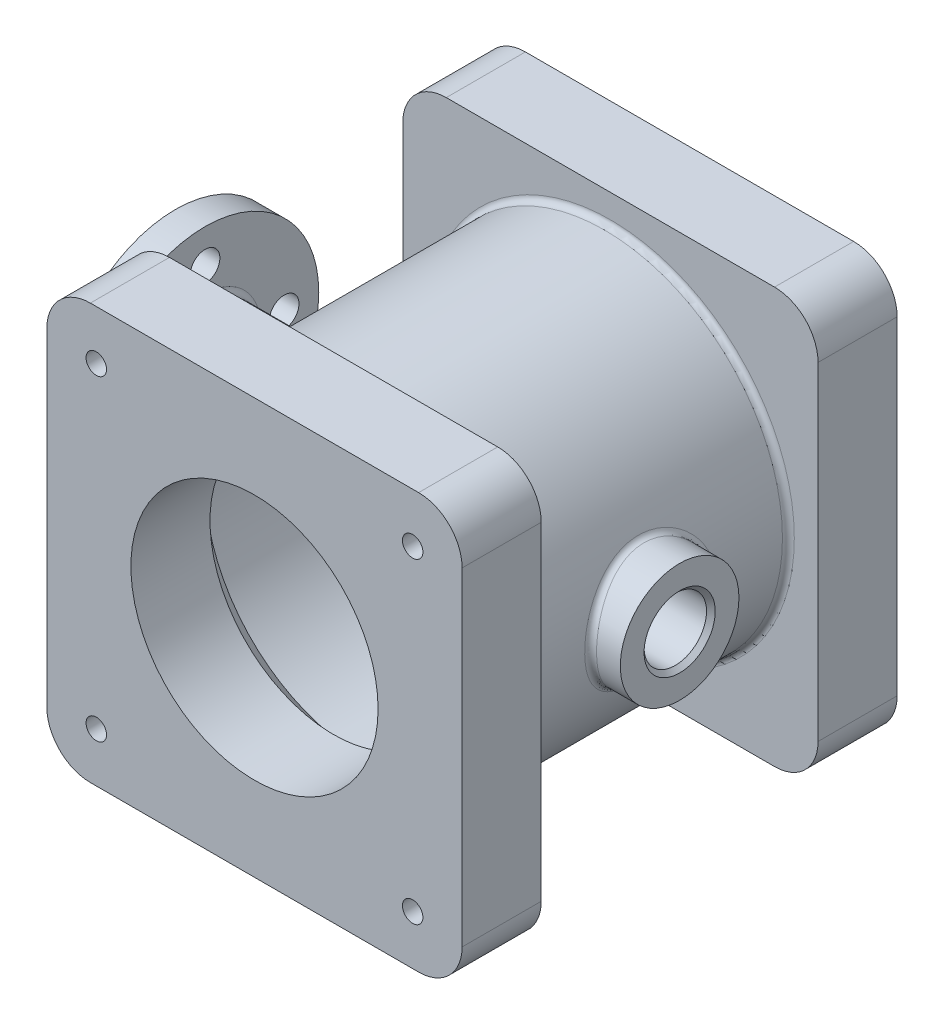
from build123d import *

# Parameters (mm, degrees)
EXTRUDE_1_DEPTH          = 40
SKETCH_2_R               = 90
SKETCH_2_R_2             = 80
EXTRUDE_2_DEPTH          = 70
CHAMFER_1_SIZE           = 15
SKETCH_3_R               = 30
CUT_EXTRUDE_1_DEPTH      = 165.164551594
SKETCH_4_R               = 5.172
CUT_EXTRUDE_2_DEPTH      = 25
SKETCH_5_R               = 62.5
CUT_EXTRUDE_3_DEPTH      = 5
SKETCH_6_R               = 62.5
EXTRUDE_3_DEPTH          = 5
CUT_EXTRUDE_4_REACH      = 267.424
SKETCH_7_R               = 62.5
EXTRUDE_START            = -150
SKETCH_8_R               = 57.5
EXTRUDE_4_DEPTH          = 15
EXTRUDE_5_REACH          = 344.089
EXTRUDE_5_END_RADIUS     = 90
SKETCH_9_R               = 25
CUT_EXTRUDE_5_REACH      = 354.775
CUT_EXTRUDE_5_END_RADIUS = 80
SKETCH_10_R              = 12.5
CUT_EXTRUDE_6_REACH      = 354.775
SKETCH_11_R              = 7.5
PATTERN_CIRCULAR_1_COUNT = 4
FILLET_1_R               = 4
EXTRUDE_6_REACH          = 354.775
EXTRUDE_6_END_RADIUS     = 90
SKETCH_12_R              = 30
CUT_EXTRUDE_7_REACH      = 354.775
CUT_EXTRUDE_7_END_RADIUS = 80
SKETCH_13_R              = 15.805
CHAMFER_2_SIZE           = 2.195
FILLET_2_R               = 3


with BuildPart() as part:
    # Эскиз1 → Бобышка-Вытянуть1 (new body)
    with BuildSketch(Plane.XY):
        with BuildLine():
            Line((-83, -105), (83, -105))
            ThreePointArc((83, -105), (98.556349186, -98.556349186), (105, -83))
            Line((105, -83), (105, 83))
            ThreePointArc((105, 83), (98.556349186, 98.556349186), (83, 105))
            Line((83, 105), (-83, 105))
            ThreePointArc((-83, 105), (-98.556349186, 98.556349186), (-105, 83))
            Line((-105, 83), (-105, -83))
            ThreePointArc((-105, -83), (-98.556349186, -98.556349186), (-83, -105))
        make_face()
    extrude(amount=EXTRUDE_1_DEPTH)

    # Эскиз2 → Бобышка-Вытянуть2 (add)
    with BuildSketch(Plane.XY.offset(40)):
        Circle(SKETCH_2_R)
        Circle(SKETCH_2_R_2, mode=Mode.SUBTRACT)
    extrude(amount=EXTRUDE_2_DEPTH)

    # Фаска1
    chamfer_1_edges = [part.edges().sort_by_distance(p)[0] for p in [
        (-80, 0, 40),
    ]]
    chamfer(chamfer_1_edges, length=CHAMFER_1_SIZE)

    # Эскиз3 → Вырез-Вытянуть1 (cut, through all)
    with BuildSketch(Plane.XY.offset(40)):
        Circle(SKETCH_3_R)
    extrude(amount=-CUT_EXTRUDE_1_DEPTH, mode=Mode.SUBTRACT)

    # Эскиз4 → Вырез-Вытянуть2 (cut)
    with BuildSketch(Plane(origin=(0, 0, 0), x_dir=(-1, 0, 0), z_dir=(0, 0, -1))):
        with Locations((-80, 80)):
            Circle(SKETCH_4_R)
        with Locations((80, 80)):
            Circle(SKETCH_4_R)
        with Locations((80, -80)):
            Circle(SKETCH_4_R)
        with Locations((-80, -80)):
            Circle(SKETCH_4_R)
    extrude(amount=-CUT_EXTRUDE_2_DEPTH, mode=Mode.SUBTRACT)

    # Эскиз5 → Вырез-Вытянуть3 (cut)
    with BuildSketch(Plane(origin=(0, 0, 0), x_dir=(-1, 0, 0), z_dir=(0, 0, -1))):
        Circle(SKETCH_5_R)
    extrude(amount=-CUT_EXTRUDE_3_DEPTH, mode=Mode.SUBTRACT)

    # Зеркальное отражение1: part across plane


with BuildPart() as part_1:
    add(part.part)
    add(part.part.mirror(Plane.XY.offset(110)))

    # Эскиз6 → Бобышка-Вытянуть3 (add)
    with BuildSketch(Plane.XY.offset(215)):
        with Locations(Location((0, 0, 0), (0, 0, 180))):
            Circle(SKETCH_6_R)
    extrude(amount=EXTRUDE_3_DEPTH)

    # Эскиз7 → Вырез-Вытянуть4 (cut, up to next)
    with BuildSketch(Plane.XY.offset(220), mode=Mode.PRIVATE) as cut_extrude_4_sk1:
        with Locations(Location((0, 0, 0), (0, 0, 180))):
            Circle(SKETCH_7_R)
    cut_extrude_4_tool1 = extrude(cut_extrude_4_sk1.sketch, amount=-CUT_EXTRUDE_4_REACH, mode=Mode.PRIVATE) & part_1.part
    add(cut_extrude_4_tool1.solids().sort_by_distance((0, 0, 220))[0], mode=Mode.SUBTRACT)



with BuildPart() as body_2:
    # Эскиз8 → Бобышка-Вытянуть4 (new body)
    with BuildSketch(Plane(origin=(0, 0, 0), x_dir=(0, 0, -1), z_dir=(1, 0, 0)).offset(EXTRUDE_START)):
        with Locations((-110, 0)):
            Circle(SKETCH_8_R)
    extrude(amount=EXTRUDE_4_DEPTH)


with BuildPart() as part_2:
    add(part_1.part)

    add(body_2.part)  # Бобышка-Вытянуть5 merges body 2
    # Бобышка-Вытянуть5: up to this cylinder (the profile starts outside it)
    extrude_5_end = Plane(origin=(0, 0, 110), z_dir=(0, 0, -1)) * Cylinder(EXTRUDE_5_END_RADIUS, 869.178, mode=Mode.PRIVATE)
    # Эскиз9 → Бобышка-Вытянуть5 (add, up to the surface)
    with BuildSketch(Plane(origin=(-135, 0, 0), x_dir=(0, 0, -1), z_dir=(1, 0, 0)), mode=Mode.PRIVATE) as extrude_5_sk1:
        with Locations(Location((-110, 0, 0), (0, 0, 180))):
            Circle(SKETCH_9_R)
    extrude_5_tool1 = extrude(extrude_5_sk1.sketch, amount=EXTRUDE_5_REACH, mode=Mode.PRIVATE) - extrude_5_end
    add(extrude_5_tool1.solids().sort_by_distance((-135, 0, 110))[0])

    # Вырез-Вытянуть5: up to this cylinder (the profile starts outside it)
    cut_extrude_5_end = Plane(origin=(0, 0, 110), z_dir=(0, 0, -1)) * Cylinder(CUT_EXTRUDE_5_END_RADIUS, 870.55, mode=Mode.PRIVATE)
    # Эскиз10 → Вырез-Вытянуть5 (cut, up to the surface)
    with BuildSketch(Plane.ZY.offset(150), mode=Mode.PRIVATE) as cut_extrude_5_sk1:
        with Locations((110, 0)):
            Circle(SKETCH_10_R)
    cut_extrude_5_tool1 = extrude(cut_extrude_5_sk1.sketch, amount=-CUT_EXTRUDE_5_REACH, mode=Mode.PRIVATE) - cut_extrude_5_end
    add(cut_extrude_5_tool1.solids().sort_by_distance((-150, 0, 110))[0], mode=Mode.SUBTRACT)

    # Эскиз11 → Вырез-Вытянуть6 (cut, up to next)
    with BuildSketch(Plane.ZY.offset(150), mode=Mode.PRIVATE) as cut_extrude_6_sk1:
        with Locations((110, 40)):
            Circle(SKETCH_11_R)
    cut_extrude_6_tool1 = extrude(cut_extrude_6_sk1.sketch, amount=-CUT_EXTRUDE_6_REACH, mode=Mode.PRIVATE) & part_2.part
    cut_extrude_6 = cut_extrude_6_tool1.solids().sort_by_distance((-150, 40, 110))[0]
    add(cut_extrude_6, mode=Mode.SUBTRACT)

    # Круговой массив1: Вырез-Вытянуть6 ×4 about axis
    pattern_circular_1_axis = Axis((0, 0, 110), (1, 0, 0))
    for i in range(1, PATTERN_CIRCULAR_1_COUNT):
        add(cut_extrude_6.rotate(pattern_circular_1_axis, i * 360 / PATTERN_CIRCULAR_1_COUNT), mode=Mode.SUBTRACT)

    # Скругление1
    fillet_1_edges = [part_2.edges().sort_by_distance(p)[0] for p in [
        (-80, 0, 97.5),
    ]]
    fillet(fillet_1_edges, radius=FILLET_1_R)

    # Бобышка-Вытянуть6: up to this cylinder (the profile starts outside it)
    extrude_6_end = Plane(origin=(0, 0, 110), z_dir=(0, 0, -1)) * Cylinder(EXTRUDE_6_END_RADIUS, 890.55, mode=Mode.PRIVATE)
    # Эскиз12 → Бобышка-Вытянуть6 (add, up to the surface)
    with BuildSketch(Plane(origin=(105, 0, 0), x_dir=(0, 0, -1), z_dir=(1, 0, 0)), mode=Mode.PRIVATE) as extrude_6_sk1:
        with Locations((-110, 0)):
            Circle(SKETCH_12_R)
    extrude_6_tool1 = extrude(extrude_6_sk1.sketch, amount=-EXTRUDE_6_REACH, mode=Mode.PRIVATE) - extrude_6_end
    add(extrude_6_tool1.solids().sort_by_distance((105, 0, 110))[0])

    # Вырез-Вытянуть7: up to this cylinder (the profile starts outside it)
    cut_extrude_7_end = Plane(origin=(0, 0, 110), z_dir=(0, 0, -1)) * Cylinder(CUT_EXTRUDE_7_END_RADIUS, 870.55, mode=Mode.PRIVATE)
    # Эскиз13 → Вырез-Вытянуть7 (cut, up to the surface)
    with BuildSketch(Plane(origin=(105, 0, 0), x_dir=(0, 0, -1), z_dir=(1, 0, 0)), mode=Mode.PRIVATE) as cut_extrude_7_sk1:
        with Locations((-110, 0)):
            Circle(SKETCH_13_R)
    cut_extrude_7_tool1 = extrude(cut_extrude_7_sk1.sketch, amount=-CUT_EXTRUDE_7_REACH, mode=Mode.PRIVATE) - cut_extrude_7_end
    add(cut_extrude_7_tool1.solids().sort_by_distance((105, 0, 110))[0], mode=Mode.SUBTRACT)

    # Фаска2
    chamfer_2_edges = [part_2.edges().sort_by_distance(p)[0] for p in [
        (105, 0, 125.805),
    ]]
    chamfer(chamfer_2_edges, length=CHAMFER_2_SIZE)

    # Скругление2
    fillet_2_edges = [part_2.edges().sort_by_distance(p)[0] for p in [
        (-90, 0, 85),
        (-135, 0, 85),
        (84.852813743, -29.999999998, 110.000000001),
        (-90, 0, 40),
        (-90, 0, 180),
    ]]
    fillet(fillet_2_edges, radius=FILLET_2_R)


solid = part_2.part
